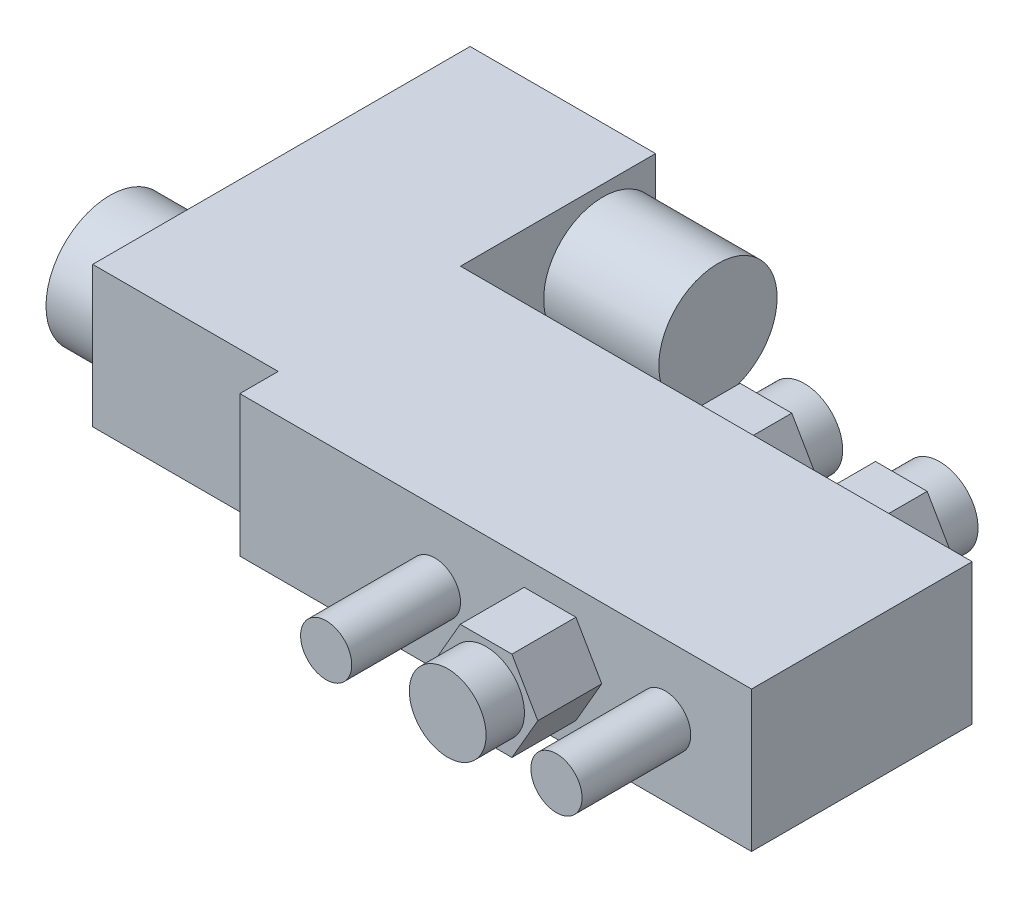
from build123d import *

# Parameters (mm, degrees)
BOSS_EXTRUDE1_DEPTH = 22
SKETCH2_R           = 4
BOSS_EXTRUDE2_DEPTH = 17
BOSS_EXTRUDE3_DEPTH = 10
SKETCH4_R           = 9.25
BOSS_EXTRUDE4_DEPTH = 18
SKETCH5_R           = 10
BOSS_EXTRUDE5_DEPTH = 9
BOSS_EXTRUDE6_DEPTH = 10
SKETCH7_R           = 6
BOSS_EXTRUDE7_DEPTH = 6
SKETCH8_R           = 6
BOSS_EXTRUDE8_DEPTH = 6


with BuildPart() as part:
    # Sketch1 → Boss-Extrude1 (new body)
    with BuildSketch(Plane(origin=(0, 0, 0), x_dir=(1, 0, 0), z_dir=(0, 1, 0))):
        Polygon((0, 0), (80, 0), (80, 34.5), (0, 34.5), (0, 65), (-29, 65), (-29, 6), (0, 6), align=None)
    extrude(amount=BOSS_EXTRUDE1_DEPTH)

    # Sketch2 → Boss-Extrude2 (add)
    with BuildSketch(Plane.XY):
        with Locations((30.5, 11)):
            Circle(SKETCH2_R)
        with Locations((66.5, 11)):
            Circle(SKETCH2_R)
    extrude(amount=BOSS_EXTRUDE2_DEPTH)

    # Sketch3 → Boss-Extrude3 (add)
    with BuildSketch(Plane(origin=(0, 0, -34.5), x_dir=(-1, 0, 0), z_dir=(0, 0, -1))):
        Polygon((-50.834192463, 11), (-54.875644347, 18), (-62.958548116, 18), (-67, 11), (-62.958548116, 4), (-54.875644347, 4), align=None)
        Polygon((-29.668384925, 11), (-33.70983681, 18), (-41.792740578, 18), (-45.834192463, 11), (-41.792740578, 4), (-33.70983681, 4), align=None)
    extrude(amount=BOSS_EXTRUDE3_DEPTH)

    # Sketch4 → Boss-Extrude4 (add)
    with BuildSketch(Plane(origin=(0, 0, 0), x_dir=(0, 0, -1), z_dir=(1, 0, 0))):
        with Locations((56.75, 11)):
            Circle(SKETCH4_R)
    extrude(amount=BOSS_EXTRUDE4_DEPTH)

    # Sketch5 → Boss-Extrude5 (add)
    with BuildSketch(Plane.ZY.offset(29)):
        with Locations((-17.7, 11)):
            Circle(SKETCH5_R)
    extrude(amount=BOSS_EXTRUDE5_DEPTH)

    # Sketch6 → Boss-Extrude6 (add)
    with BuildSketch(Plane.XY):
        Polygon((56.582903769, 11), (52.541451884, 18), (44.458548116, 18), (40.417096231, 11), (44.458548116, 4), (52.541451884, 4), align=None)
    extrude(amount=BOSS_EXTRUDE6_DEPTH)

    # Sketch7 → Boss-Extrude7 (add)
    with BuildSketch(Plane.XY.offset(10)):
        with Locations((48.5, 11)):
            Circle(SKETCH7_R)
    extrude(amount=BOSS_EXTRUDE7_DEPTH)

    # Sketch8 → Boss-Extrude8 (add)
    with BuildSketch(Plane(origin=(0, 0, -44.5), x_dir=(-1, 0, 0), z_dir=(0, 0, -1))):
        with Locations((-58.917096231, 11)):
            Circle(SKETCH8_R)
        with Locations((-37.751288694, 11)):
            Circle(SKETCH8_R)
    extrude(amount=BOSS_EXTRUDE8_DEPTH)


solid = part.part
